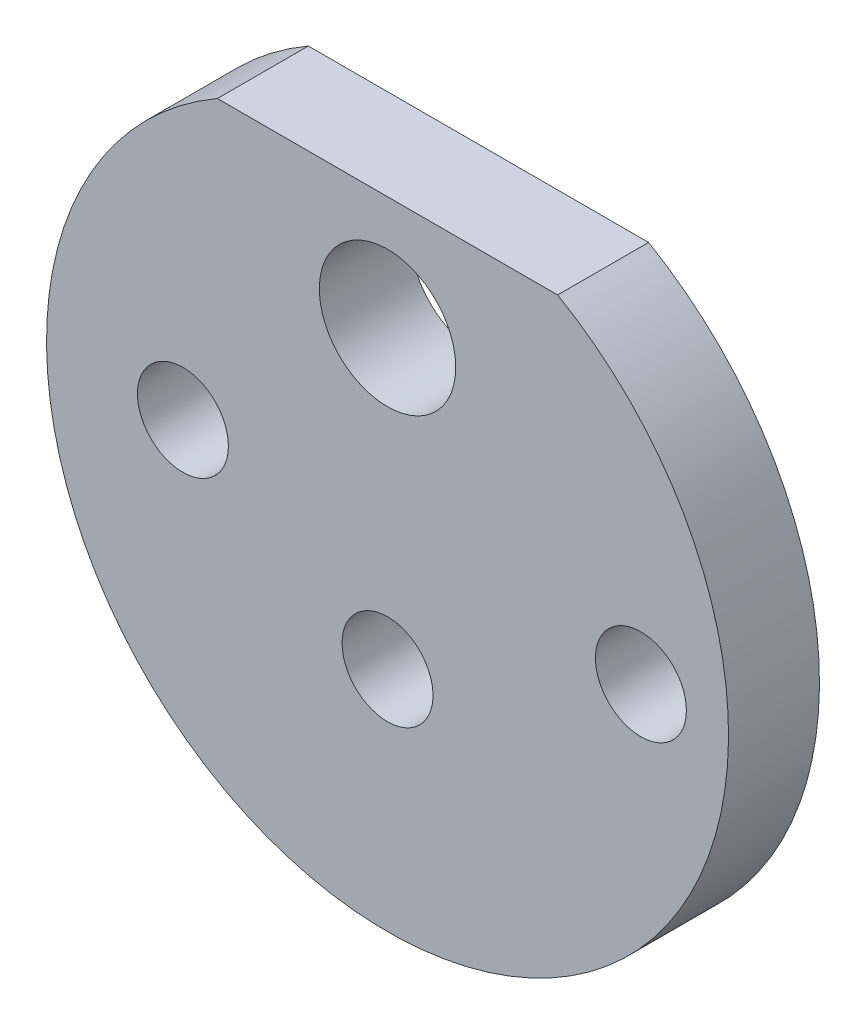
from build123d import *

# Parameters (mm, degrees)
SKETCH1_R           = 3
SKETCH1_R_2         = 2
BOSS_EXTRUDE1_DEPTH = 4
SKETCH2_R           = 6
BOSS_EXTRUDE2_DEPTH = 4
SKETCH3_R           = 2
CUT_EXTRUDE1_DEPTH  = 9
CHAMFER1_SIZE       = 0.5


with BuildPart() as part:
    # Sketch1 → Boss-Extrude1 (new body)
    with BuildSketch(Plane.XY):
        with BuildLine():
            Line((-7.483314774, 13), (7.483314774, 13))
            ThreePointArc((7.483314774, 13), (0, -15), (-7.483314774, 13))
        make_face()
        with Locations((0, 8)):
            Circle(SKETCH1_R, mode=Mode.SUBTRACT)
        with Locations((-9, 0)):
            Circle(SKETCH1_R_2, mode=Mode.SUBTRACT)
        with Locations((11.144937976, 0)):
            Circle(SKETCH1_R_2, mode=Mode.SUBTRACT)
    extrude(amount=BOSS_EXTRUDE1_DEPTH)

    # Sketch2 → Boss-Extrude2 (add)
    with BuildSketch(Plane(origin=(0, 0, 0), x_dir=(-1, 0, 0), z_dir=(0, 0, -1))):
        with Locations((0, -5)):
            Circle(SKETCH2_R)
    extrude(amount=BOSS_EXTRUDE2_DEPTH)

    # Sketch3 → Cut-Extrude1 (cut, through all)
    with BuildSketch(Plane(origin=(0, 0, -4), x_dir=(-1, 0, 0), z_dir=(0, 0, -1))):
        with Locations((0, -5)):
            Circle(SKETCH3_R)
    extrude(amount=-CUT_EXTRUDE1_DEPTH, mode=Mode.SUBTRACT)

    # Chamfer1
    chamfer1_edges = [part.edges().sort_by_distance(p)[0] for p in [
        (6, -5, -4),
    ]]
    chamfer(chamfer1_edges, length=CHAMFER1_SIZE)


solid = part.part
